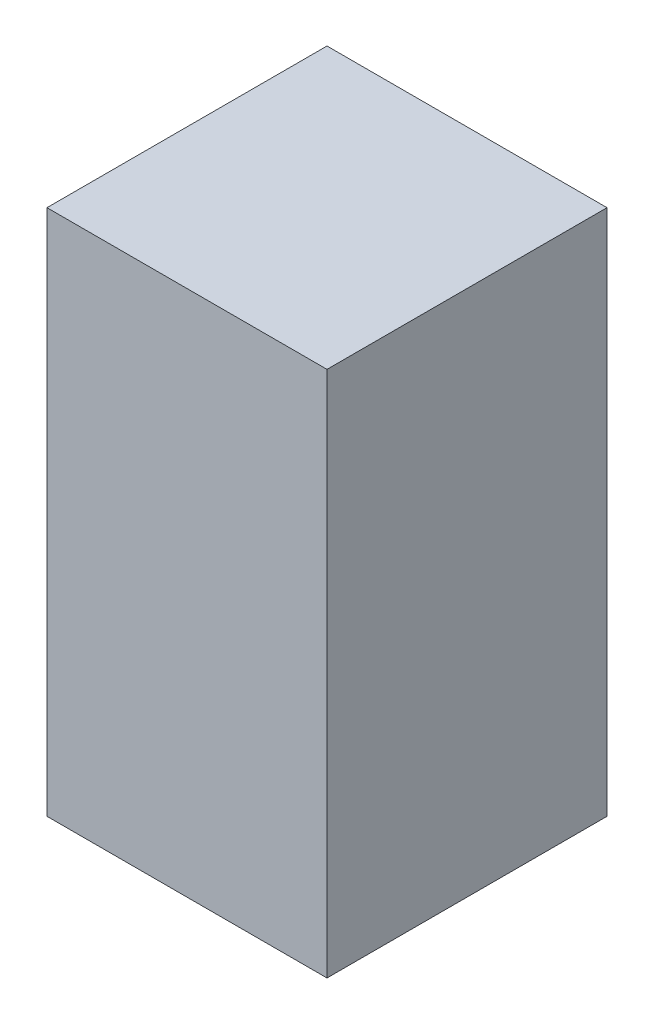
from build123d import *

# Parameters (mm, degrees)
SKETCH1_W           = 53.975
SKETCH1_H           = 53.975
BOSS_EXTRUDE1_DEPTH = 101.6


with BuildPart() as part:
    # Sketch1 → Boss-Extrude1 (new body)
    with BuildSketch(Plane(origin=(0, 0, 0), x_dir=(1, 0, 0), z_dir=(0, 1, 0))):
        Rectangle(SKETCH1_W, SKETCH1_H)
    extrude(amount=BOSS_EXTRUDE1_DEPTH)


solid = part.part
